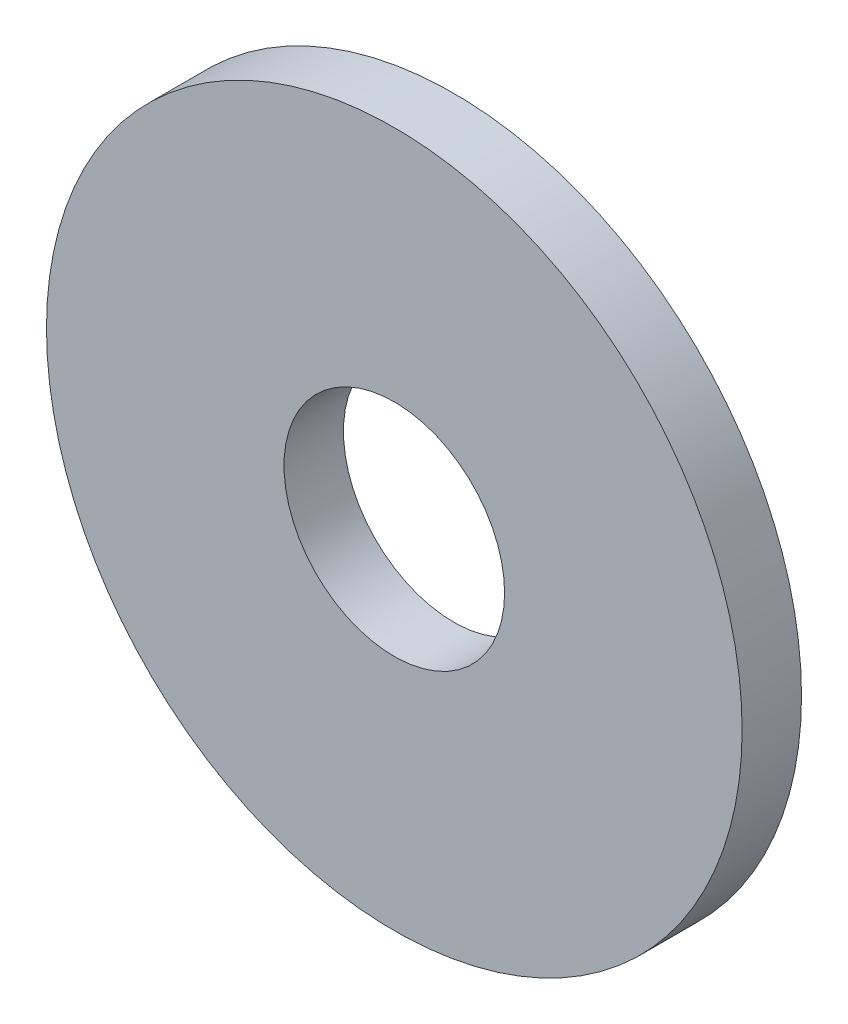
from build123d import *

# Parameters (mm, degrees)
SKICA1_R                = 16.4
SKICA1_R_2              = 5.2
P_IDAT_VYSUNUT_M1_DEPTH = 2.8


with BuildPart() as part:
    # Skica1 → Přidat vysunutím1 (new body)
    with BuildSketch(Plane.XY):
        Circle(SKICA1_R)
        Circle(SKICA1_R_2, mode=Mode.SUBTRACT)
    extrude(amount=P_IDAT_VYSUNUT_M1_DEPTH)


solid = part.part
